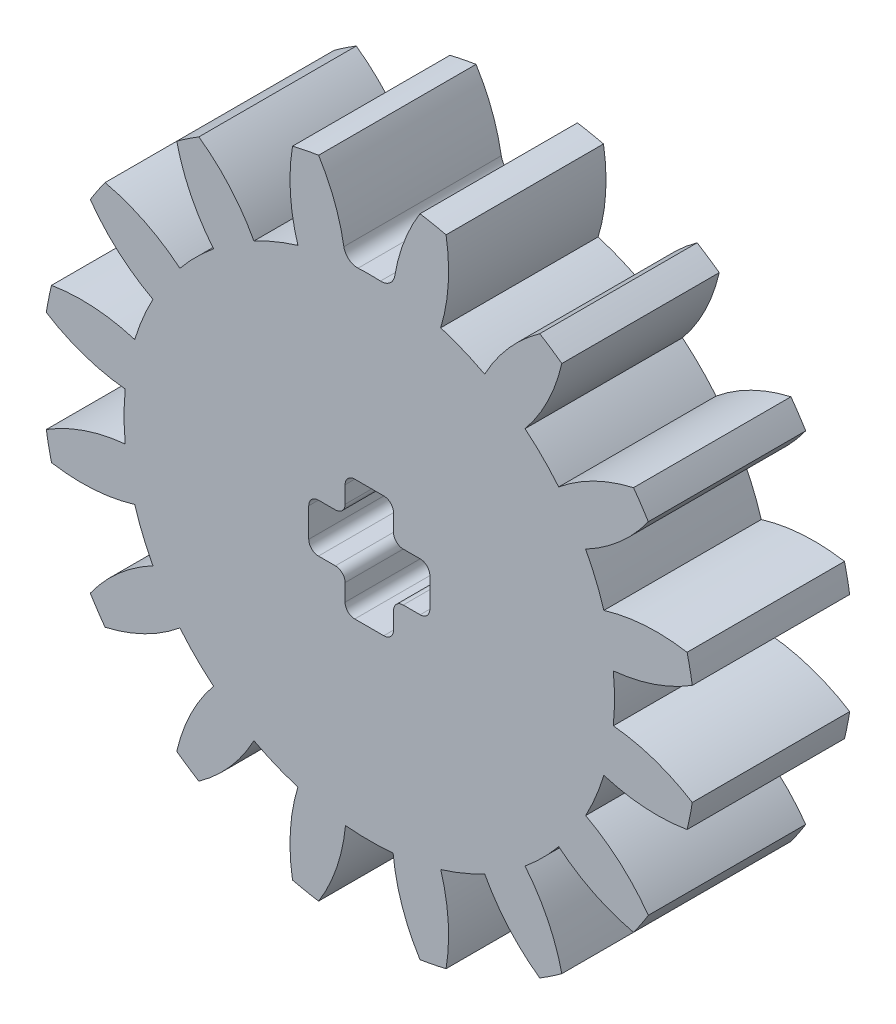
from build123d import *

# Parameters (mm, degrees)
SKETCH1_R           = 13.5
BOSS_EXTRUDE1_DEPTH = 3.25
CUT_EXTRUDE1_DEPTH  = 4.25
FILLET1_R           = 0.57
CIRPATTERN3_COUNT   = 16


with BuildPart() as part:
    # Sketch1 → Boss-Extrude1 (new body, symmetric)
    with BuildSketch(Plane.XY):
        Circle(SKETCH1_R)
        with BuildLine():
            Line((1.4, 1), (2.1, 1))
            ThreePointArc((2.1, 1), (2.382842712, 0.882842712), (2.5, 0.6))
            Line((2.5, 0.6), (2.5, -0.6))
            ThreePointArc((2.5, -0.6), (2.382842712, -0.882842712), (2.1, -1))
            Line((2.1, -1), (1.4, -1))
            ThreePointArc((1.4, -1), (1.117157288, -1.117157288), (1, -1.4))
            Line((1, -1.4), (1, -2.1))
            ThreePointArc((1, -2.1), (0.882842712, -2.382842712), (0.6, -2.5))
            Line((0.6, -2.5), (-0.6, -2.5))
            ThreePointArc((-0.6, -2.5), (-0.882842712, -2.382842712), (-1, -2.1))
            Line((-1, -2.1), (-1, -1.4))
            ThreePointArc((-1, -1.4), (-1.117157288, -1.117157288), (-1.4, -1))
            Line((-1.4, -1), (-2.1, -1))
            ThreePointArc((-2.1, -1), (-2.382842712, -0.882842712), (-2.5, -0.6))
            Line((-2.5, -0.6), (-2.5, 0.6))
            ThreePointArc((-2.5, 0.6), (-2.382842712, 0.882842712), (-2.1, 1))
            Line((-2.1, 1), (-1.4, 1))
            ThreePointArc((-1.4, 1), (-1.117157288, 1.117157288), (-1, 1.4))
            Line((-1, 1.4), (-1, 2.1))
            ThreePointArc((-1, 2.1), (-0.882842712, 2.382842712), (-0.6, 2.5))
            Line((-0.6, 2.5), (0.6, 2.5))
            ThreePointArc((0.6, 2.5), (0.882842712, 2.382842712), (1, 2.1))
            Line((1, 2.1), (1, 1.4))
            ThreePointArc((1, 1.4), (1.117157288, 1.117157288), (1.4, 1))
        make_face(mode=Mode.SUBTRACT)
    extrude(amount=BOSS_EXTRUDE1_DEPTH, both=True)

    # Sketch2 → Cut-Extrude1 (cut, symmetric)
    with BuildSketch(Plane.XY):
        with BuildLine():
            ThreePointArc((0.982234387, 10.077243701), (0, 10.125), (-0.982234387, 10.077243701))
            ThreePointArc((-0.982234387, 10.077243701), (-1.348268622, 11.771504161), (-2.092826994, 13.336794037))
            ThreePointArc((-2.092826994, 13.336794037), (0, 13.5), (2.092826994, 13.336794037))
            ThreePointArc((2.092826994, 13.336794037), (1.348268622, 11.771504161), (0.982234387, 10.077243701))
        make_face()
    cut_extrude1 = extrude(amount=CUT_EXTRUDE1_DEPTH, both=True, mode=Mode.SUBTRACT)

    # Fillet1
    fillet1_edges = [part.edges().sort_by_distance(p)[0] for p in [
        (-0.982234387, 10.077243701, 0),
        (0.982234387, 10.077243701, 0),
    ]]
    fillet(fillet1_edges, radius=FILLET1_R)

    # CirPattern3: Cut-Extrude1 ×16 about axis
    cirpattern3_axis = Axis((0, 0, 0), (0, 0, 1))
    for i in range(1, CIRPATTERN3_COUNT):
        add(cut_extrude1.rotate(cirpattern3_axis, i * 360 / CIRPATTERN3_COUNT), mode=Mode.SUBTRACT)


solid = part.part
